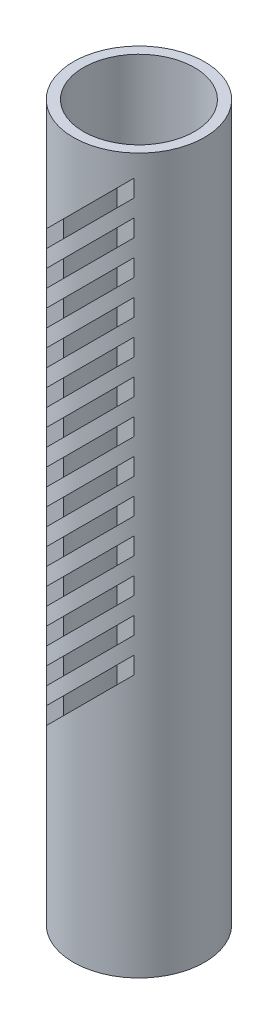
from build123d import *

# Parameters (mm, degrees)
SKETCH1_R           = 25.654
SKETCH1_R_2         = 21.717
BOSS_EXTRUDE1_DEPTH = 279.4
CUT_EXTRUDE1_START  = 19.05
CUT_EXTRUDE1_DEPTH  = 12.7
LPATTERN1_COUNT     = 13
LPATTERN1_PITCH     = 13.462


with BuildPart() as part:
    # Sketch1 → Boss-Extrude1 (new body)
    with BuildSketch(Plane(origin=(0, 0, 0), x_dir=(1, 0, 0), z_dir=(0, 1, 0))):
        Circle(SKETCH1_R)
        Circle(SKETCH1_R_2, mode=Mode.SUBTRACT)
    extrude(amount=BOSS_EXTRUDE1_DEPTH)

    # Sketch2 → Cut-Extrude1 (cut)
    with BuildSketch(Plane.XY.offset(CUT_EXTRUDE1_START)):
        Polygon((-29.021596045, 224.724403955), (-25.654, 221.356807909), (29.021596045, 276.032403955), (25.654, 279.4), align=None)
    cut_extrude1 = extrude(amount=CUT_EXTRUDE1_DEPTH, mode=Mode.SUBTRACT)

    # LPattern1: Cut-Extrude1 ×13
    with Locations(*[(0, -i * LPATTERN1_PITCH, 0) for i in range(1, LPATTERN1_COUNT)]):
        add(cut_extrude1, mode=Mode.SUBTRACT)


solid = part.part
